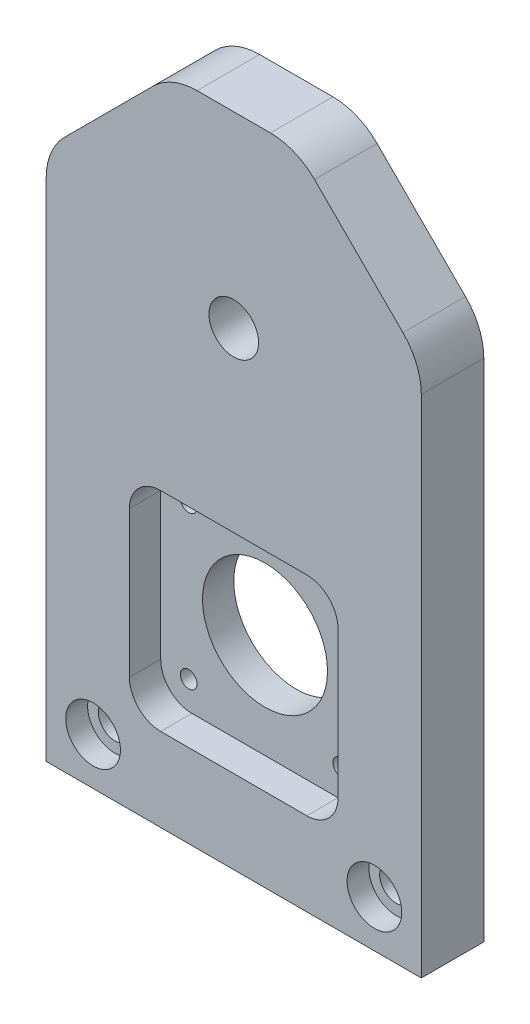
from build123d import *

# Parameters (mm, degrees)
SKETCH2_W                                        = 76.2
SKETCH2_H                                        = 133.35
BOSS_EXTRUDE1_DEPTH                              = 6.35
F_3_8_CLEARANCE_HOLE1_D                          = 10.0838
M3_CLEARANCE_HOLE1_D                             = 3.4
SKETCH13_R                                       = 12.7
CUT_EXTRUDE2_DEPTH                               = 13.7
SKETCH14_W                                       = 42.381000074
SKETCH14_H                                       = 42.381000074
CUT_EXTRUDE3_DEPTH                               = 6.35
CHAMFER1_SIZE                                    = 25.4
CBORE_FOR_1_4_SOCKET_HEAD_CAP_SCREW1_D           = 6.7564
CBORE_FOR_1_4_SOCKET_HEAD_CAP_SCREW1_CBORE_D     = 11.1125
CBORE_FOR_1_4_SOCKET_HEAD_CAP_SCREW1_CBORE_DEPTH = 4.445
CBORE_FOR_M3_SHCS1_D                             = 3.4
CBORE_FOR_M3_SHCS1_CBORE_D                       = 6.5
CBORE_FOR_M3_SHCS1_CBORE_DEPTH                   = 3
FILLET1_R                                        = 6.35
FILLET2_R                                        = 12.7


with BuildPart() as part:
    # Sketch2 → Boss-Extrude1 (new body, symmetric)
    with BuildSketch(Plane.XY):
        with Locations((0, -28.575)):
            Rectangle(SKETCH2_W, SKETCH2_H)
    extrude(amount=BOSS_EXTRUDE1_DEPTH, both=True)

    # 3/8 Clearance Hole1 (through all)
    with Locations(Plane.XY.offset(6.35)):
        with Locations((0, 0)):
            Hole(F_3_8_CLEARANCE_HOLE1_D / 2)

    # M3 Clearance Hole1 (through all)
    with Locations(Plane.XY.offset(6.35)):
        with Locations((-15.5, -41.65), (15.5, -41.65), (15.5, -72.65), (-15.5, -72.65)):
            Hole(M3_CLEARANCE_HOLE1_D / 2)

    # Sketch13 → Cut-Extrude2 (cut, through all)
    with BuildSketch(Plane.XY.offset(6.35)):
        with Locations((0, -57.15)):
            Circle(SKETCH13_R)
    extrude(amount=-CUT_EXTRUDE2_DEPTH, mode=Mode.SUBTRACT)

    # Sketch14 → Cut-Extrude3 (cut)
    with BuildSketch(Plane.XY.offset(6.35)):
        with Locations((0, -57.15)):
            Rectangle(SKETCH14_W, SKETCH14_H)
    extrude(amount=-CUT_EXTRUDE3_DEPTH, mode=Mode.SUBTRACT)

    # Chamfer1
    chamfer1_edges = [part.edges().sort_by_distance(p)[0] for p in [
        (-38.1, 38.1, 0),
        (38.1, 38.1, 0),
    ]]
    chamfer(chamfer1_edges, length=CHAMFER1_SIZE)

    # CBORE for 1/4 Socket Head Cap Screw1 (through all)
    with Locations(Plane.XY.offset(6.35)):
        with Locations((-28.575, -85.725), (28.575, -85.725)):
            CounterBoreHole(CBORE_FOR_1_4_SOCKET_HEAD_CAP_SCREW1_D / 2, CBORE_FOR_1_4_SOCKET_HEAD_CAP_SCREW1_CBORE_D / 2, CBORE_FOR_1_4_SOCKET_HEAD_CAP_SCREW1_CBORE_DEPTH)

    # CBORE for M3 SHCS1 (through all)
    with Locations(Plane(origin=(0, 0, -6.35), x_dir=(-1, 0, 0), z_dir=(0, 0, -1))):
        with Locations((-15.5, -41.65), (15.5, -41.65), (15.5, -72.65), (-15.5, -72.65)):
            CounterBoreHole(CBORE_FOR_M3_SHCS1_D / 2, CBORE_FOR_M3_SHCS1_CBORE_D / 2, CBORE_FOR_M3_SHCS1_CBORE_DEPTH)

    # Fillet1
    fillet1_edges = [part.edges().sort_by_distance(p)[0] for p in [
        (-21.190500037, -35.959499963, 3.175),
        (-21.190500037, -78.340500037, 3.175),
        (21.190500037, -78.340500037, 3.175),
        (21.190500037, -35.959499963, 3.175),
    ]]
    fillet(fillet1_edges, radius=FILLET1_R)

    # Fillet2
    fillet2_edges = [part.edges().sort_by_distance(p)[0] for p in [
        (-12.7, 38.1, 0),
        (12.7, 38.1, 0),
        (38.1, 12.7, 0),
        (-38.1, 12.7, 0),
    ]]
    fillet(fillet2_edges, radius=FILLET2_R)


solid = part.part
